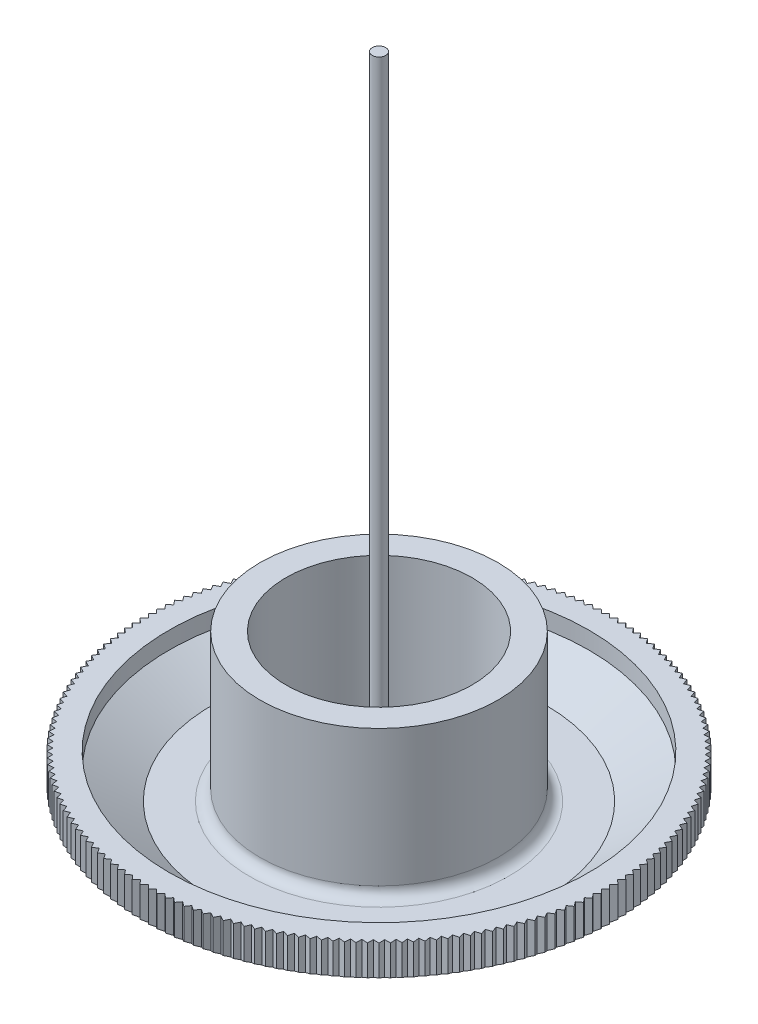
from build123d import *

# Parameters (mm, degrees)
CUT_EXTRUDE1_DEPTH  = 41.836770514
CIRPATTERN1_COUNT   = 180
BOSS_EXTRUDE1_DEPTH = 0.254
CIRPATTERN2_COUNT   = 3
SKETCH4_R           = 0.79375
BOSS_EXTRUDE2_DEPTH = 76.2


with BuildPart() as part:
    # Sketch1 → Base-Revolve (revolve)
    with BuildSketch(Plane.XY, mode=Mode.PRIVATE) as base_revolve_sk:
        with BuildLine():
            Line((0, 0), (19.939, 0))
            Line((19.939, 0), (27.559, 4.572))
            Line((27.559, 4.572), (27.559, 8.128))
            Line((27.559, 8.128), (24.638, 8.128))
            Line((24.638, 8.128), (24.638, 6.096))
            Line((24.638, 6.096), (19.558, 3.048))
            Line((19.558, 3.048), (15.24, 3.048))
            ThreePointArc((15.24, 3.048), (14.341974388, 3.419974388), (13.97, 4.318))
            Line((13.97, 4.318), (13.97, 20.32))
            Line((13.97, 20.32), (10.922, 20.32))
            Line((10.922, 20.32), (10.922, 3.048))
            Line((10.922, 3.048), (0, 3.048))
            Line((0, 3.048), (0, 0))
        make_face()
    revolve(base_revolve_sk.sketch.rotate(Axis((0, 0, 0), (0, 1, 0)), 90), axis=Axis((0, 0, 0), (0, 1, 0)))

    # Sketch2 → Cut-Extrude1 (cut, through all)
    with BuildSketch(Plane(origin=(0, 8.128, 0), x_dir=(-1, 0, 0), z_dir=(0, 1, 0))):
        Polygon((95.002266888, -122.07609865), (0.480970869, -27.554802631), (0, -27.073831762), (-0.480970869, -27.554802631), (-95.002266888, -122.07609865), (-95.002266888, -389.422696177), (95.002266888, -389.422696177), align=None)
    cut_extrude1 = extrude(amount=-CUT_EXTRUDE1_DEPTH, mode=Mode.SUBTRACT)

    # CirPattern1: Cut-Extrude1 ×180 about axis
    cirpattern1_axis = Axis((0, 53.048, 0), (0, -1, 0))
    for i in range(1, CIRPATTERN1_COUNT):
        add(cut_extrude1.rotate(cirpattern1_axis, i * 360 / CIRPATTERN1_COUNT), mode=Mode.SUBTRACT)

    # Sketch3 → Boss-Extrude1 (add)
    with BuildSketch(Plane.XZ):
        with BuildLine():
            Line((15.557122219, -5.334), (17.462122219, 0))
            Line((17.462122219, 0), (16.383, 0))
            ThreePointArc((16.383, 0), (14.18809419, 8.1915), (8.1915, 14.18809419))
            Line((8.1915, 14.18809419), (7.366, 12.758286249))
            ThreePointArc((7.366, 12.758286249), (12.758286249, 7.366), (14.732, 0))
            Line((14.732, 0), (13.652122219, 0))
            Line((13.652122219, 0), (15.557122219, -5.334))
        make_face()
    boss_extrude1 = extrude(amount=BOSS_EXTRUDE1_DEPTH)

    # CirPattern2: Boss-Extrude1 ×3 about axis
    cirpattern2_axis = Axis((0, 53.048, 0), (0, -1, 0))
    for i in range(1, CIRPATTERN2_COUNT):
        add(boss_extrude1.rotate(cirpattern2_axis, i * 360 / CIRPATTERN2_COUNT))

    # Sketch4 → Boss-Extrude2 (add)
    with BuildSketch(Plane(origin=(0, 3.048, 0), x_dir=(-1, 0, 0), z_dir=(0, 1, 0))):
        with Locations(Location((0, 0, 0), (0, 0, 270))):
            Circle(SKETCH4_R)
    extrude(amount=BOSS_EXTRUDE2_DEPTH)


solid = part.part
